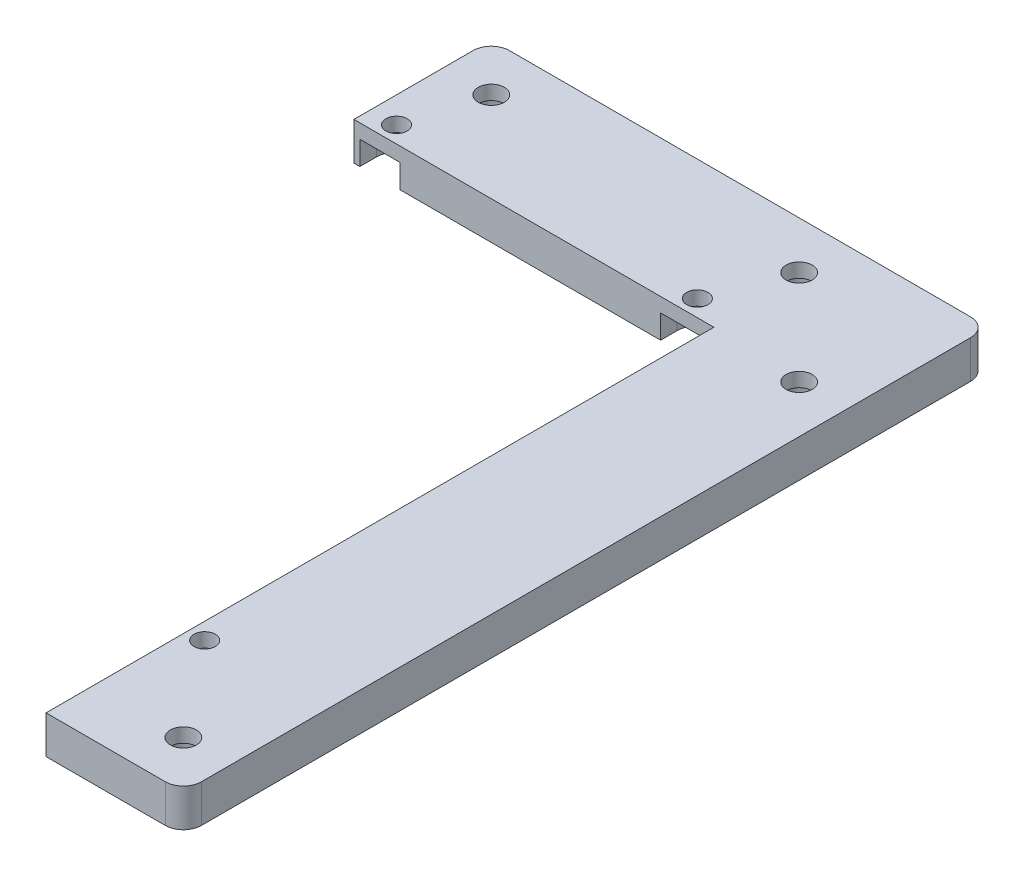
from build123d import *

# Parameters (mm, degrees)
BOSS_EXTRUDE1_DEPTH      = 4
BOSS_EXTRUDE1_DEPTH_BACK = 4
SKETCH1_R                = 2.75
SKETCH1_R_2              = 2.25
SKETCH2_R                = 4.25
CUT_EXTRUDE1_DEPTH       = 5


with BuildPart() as part:
    # Sketch1 → Boss-Extrude1 (new, two sides: drawn at the far end of the back side and taken through both)
    with BuildSketch(Plane(origin=(0, 0, 0), x_dir=(1, 0, 0), z_dir=(0, 1, 0)).offset(-BOSS_EXTRUDE1_DEPTH_BACK)):
        with BuildLine():
            Line((-52.5, 81.188228139), (-52.5, 56))
            Line((-52.5, 56), (23.5, 56))
            Line((23.5, 56), (23.5, -85))
            Line((23.5, -85), (48.688228139, -85))
            ThreePointArc((48.688228139, -85), (51.38355787, -83.88355787), (52.5, -81.188228139))
            Line((52.5, -81.188228139), (52.5, 81.188228139))
            ThreePointArc((52.5, 81.188228139), (51.38355787, 83.88355787), (48.688228139, 85))
            Line((48.688228139, 85), (-48.688228139, 85))
            ThreePointArc((-48.688228139, 85), (-51.38355787, 83.88355787), (-52.5, 81.188228139))
        make_face()
        with Locations((42.5, -75)):
            Circle(SKETCH1_R, mode=Mode.SUBTRACT)
        with Locations((27, -55)):
            Circle(SKETCH1_R_2, mode=Mode.SUBTRACT)
        with Locations((-47, 59.5)):
            Circle(SKETCH1_R_2, mode=Mode.SUBTRACT)
        with Locations((-42.5, 75)):
            Circle(SKETCH1_R, mode=Mode.SUBTRACT)
        with Locations((16.5, 59.5)):
            Circle(SKETCH1_R_2, mode=Mode.SUBTRACT)
        with Locations((22.5, 75)):
            Circle(SKETCH1_R, mode=Mode.SUBTRACT)
        with Locations((42.5, 55)):
            Circle(SKETCH1_R, mode=Mode.SUBTRACT)
    extrude(amount=BOSS_EXTRUDE1_DEPTH + BOSS_EXTRUDE1_DEPTH_BACK)

    # Sketch2 → Cut-Extrude1 (cut)
    with BuildSketch(Plane.XZ.offset(4)):
        with Locations((42.5, 75)):
            Circle(SKETCH2_R)
        with Locations((42.5, -55)):
            Circle(SKETCH2_R)
        with Locations((22.5, -75)):
            Circle(SKETCH2_R)
        with Locations((-42.5, -75)):
            Circle(SKETCH2_R)
        with BuildLine():
            Line((27, 59.25), (23.5, 59.25))
            Line((23.5, 59.25), (23.5, 50.75))
            Line((23.5, 50.75), (27, 50.75))
            ThreePointArc((27, 50.75), (31.25, 55), (27, 59.25))
        make_face()
        with BuildLine():
            Line((12.25, -59.5), (12.25, -56))
            Line((12.25, -56), (20.75, -56))
            Line((20.75, -56), (20.75, -59.5))
            ThreePointArc((20.75, -59.5), (16.5, -63.75), (12.25, -59.5))
        make_face()
        with BuildLine():
            Line((-51.25, -59.5), (-51.25, -56))
            Line((-51.25, -56), (-42.75, -56))
            Line((-42.75, -56), (-42.75, -59.5))
            ThreePointArc((-42.75, -59.5), (-47, -63.75), (-51.25, -59.5))
        make_face()
    extrude(amount=-CUT_EXTRUDE1_DEPTH, mode=Mode.SUBTRACT)


solid = part.part
